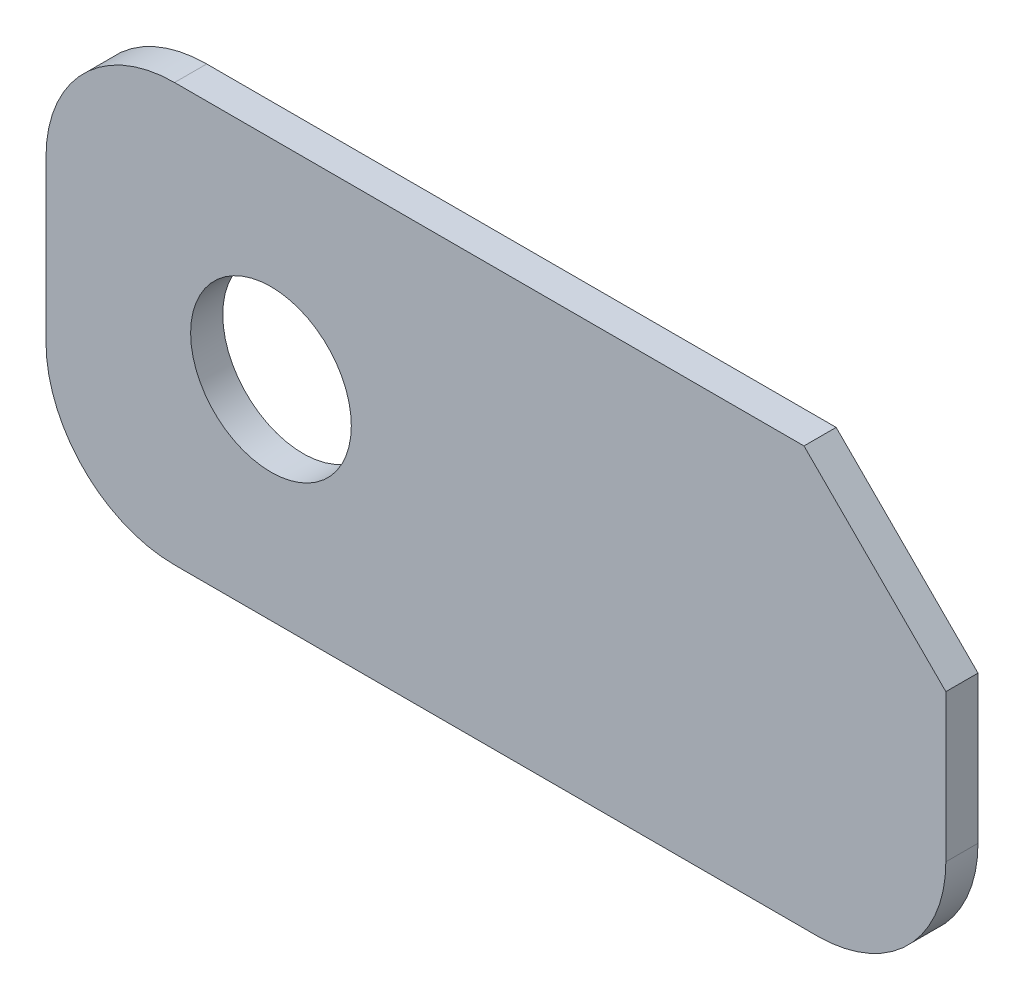
from build123d import *

# Parameters (mm, degrees)
BOSS_EXTRUDE1_DEPTH = 2
SKETCH2_R           = 5
CUT_EXTRUDE1_DEPTH  = 4.1


with BuildPart() as part:
    # Sketch1 → Boss-Extrude1 (new body)
    with BuildSketch(Plane.XY):
        with BuildLine():
            Line((-50.768947103, -2.903737712), (-11.597374228, -2.903737712))
            Line((-11.597374228, -2.903737712), (-2.768947103, -11.732164837))
            Line((-2.768947103, -11.732164837), (-2.768947103, -20.903737712))
            ThreePointArc((-2.768947103, -20.903737712), (-5.112092854, -26.560591962), (-10.768947103, -28.903737712))
            Line((-10.768947103, -28.903737712), (-50.768947103, -28.903737712))
            ThreePointArc((-50.768947103, -28.903737712), (-56.425801353, -26.560591962), (-58.768947103, -20.903737712))
            Line((-58.768947103, -20.903737712), (-58.768947103, -10.903737712))
            ThreePointArc((-58.768947103, -10.903737712), (-56.425801353, -5.246883463), (-50.768947103, -2.903737712))
        make_face()
    extrude(amount=BOSS_EXTRUDE1_DEPTH)

    # Sketch2 → Cut-Extrude1 (cut)
    with BuildSketch(Plane(origin=(0, 0, 0), x_dir=(-1, 0, 0), z_dir=(0, 0, -1))):
        with Locations((44.768947103, -15.903737712)):
            Circle(SKETCH2_R)
    extrude(amount=-CUT_EXTRUDE1_DEPTH, mode=Mode.SUBTRACT)


solid = part.part
